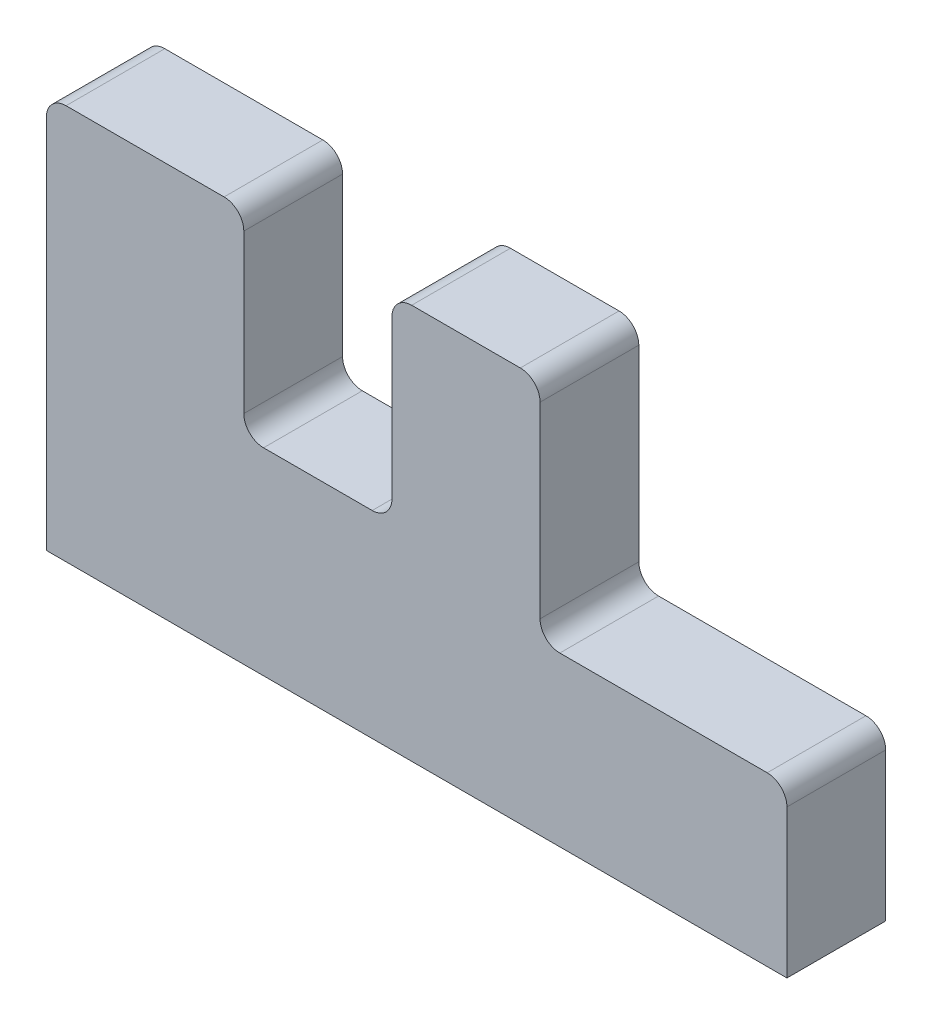
from build123d import *

# Parameters (mm, degrees)
BOSS_EXTRUDE1_DEPTH = 12.7
FILLET1_R           = 2.54


with BuildPart() as part:
    # Sketch1 → Boss-Extrude1 (new body)
    with BuildSketch(Plane.XY):
        Polygon((0, 0), (0, 50.8), (25.4, 50.8), (25.4, 25.4), (44.45, 25.4), (44.45, 50.8), (63.5, 50.8), (63.5, 21.59), (95.25, 21.59), (95.25, 0), align=None)
    extrude(amount=BOSS_EXTRUDE1_DEPTH)

    # Fillet1
    fillet1_edges = [part.edges().sort_by_distance(p)[0] for p in [
        (0, 50.8, 6.35),
        (25.4, 50.8, 6.35),
        (25.4, 25.4, 6.35),
        (44.45, 25.4, 6.35),
        (44.45, 50.8, 6.35),
        (63.5, 50.8, 6.35),
        (63.5, 21.59, 6.35),
        (95.25, 21.59, 6.35),
    ]]
    fillet(fillet1_edges, radius=FILLET1_R)


solid = part.part
